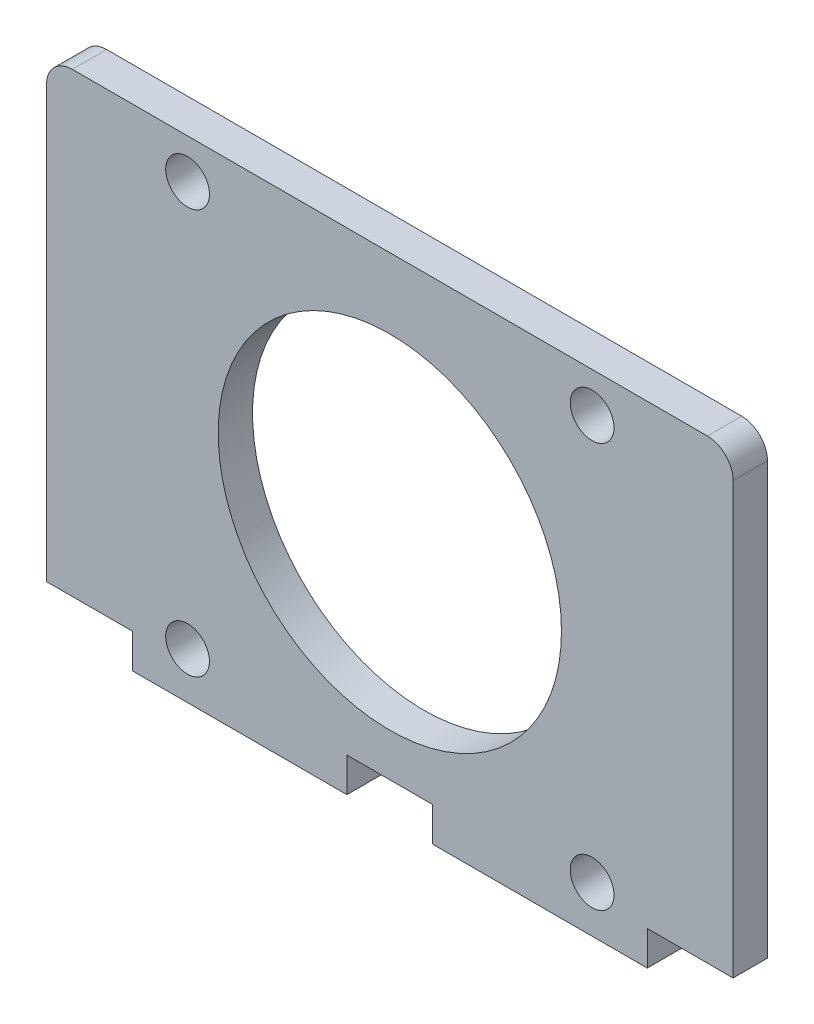
from build123d import *

# Parameters (mm, degrees)
SKETCH_1_R      = 20
SKETCH_1_R_2    = 2.55
EXTRUDE_2_DEPTH = 4
FILLET_1_R      = 3


with BuildPart() as part:
    # Эскиз1 → Бобышка-Вытянуть2 (new body)
    with BuildSketch(Plane.XY):
        Polygon((-40, 0), (40, 0), (40, -53.2), (30, -53.2), (30, -57.2), (5, -57.2), (5, -53.2), (-5, -53.2), (-5, -57.2), (-30, -57.2), (-30, -53.2), (-40, -53.2), align=None)
        with Locations((0, -28.2)):
            Circle(SKETCH_1_R, mode=Mode.SUBTRACT)
        with Locations((-23.57, -4.63)):
            Circle(SKETCH_1_R_2, mode=Mode.SUBTRACT)
        with Locations((23.57, -4.63)):
            Circle(SKETCH_1_R_2, mode=Mode.SUBTRACT)
        with Locations((23.57, -51.77)):
            Circle(SKETCH_1_R_2, mode=Mode.SUBTRACT)
        with Locations((-23.57, -51.77)):
            Circle(SKETCH_1_R_2, mode=Mode.SUBTRACT)
    extrude(amount=EXTRUDE_2_DEPTH)

    # Скругление1
    fillet_1_edges = [part.edges().sort_by_distance(p)[0] for p in [
        (-40, 0, 2),
        (40, 0, 2),
    ]]
    fillet(fillet_1_edges, radius=FILLET_1_R)


solid = part.part
